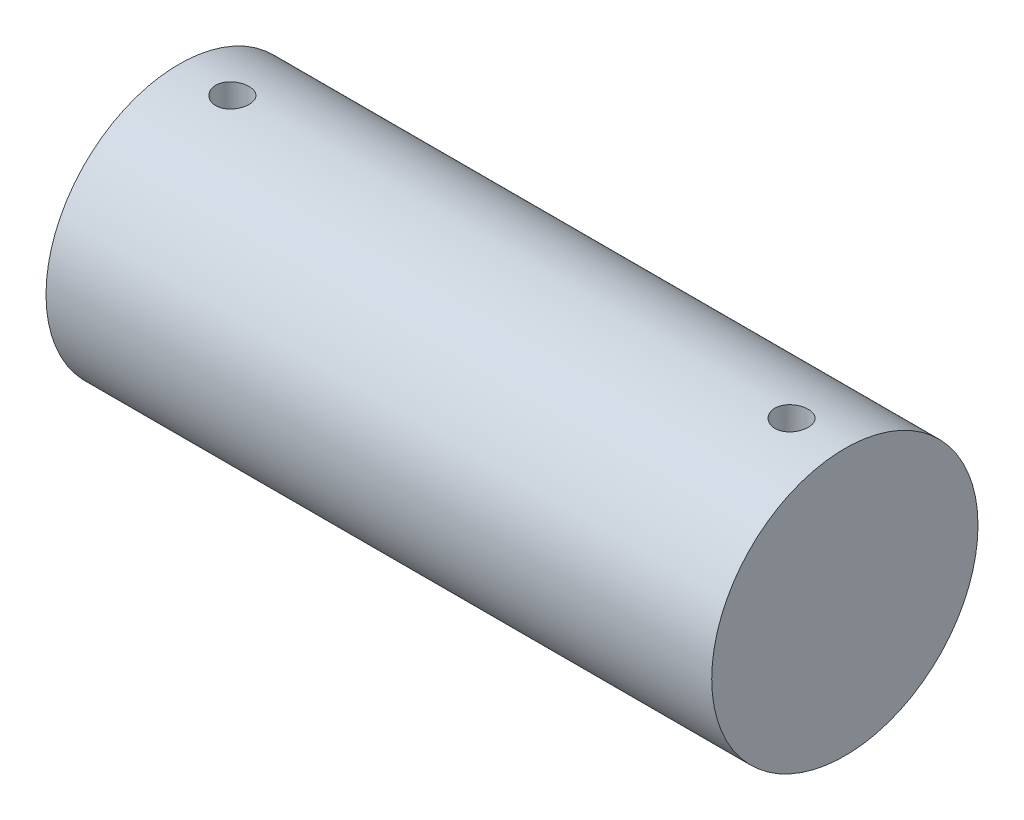
from build123d import *

# Parameters (mm, degrees)
IZIM1_R                     = 2
Y_KSEKLIK_EKSTR_ZYON1_DEPTH = 10
KES_EKSTR_ZYON1_DEPTH       = 10
KES_EKSTR_ZYON1_DEPTH_BACK  = 10
IZIM2_R                     = 0.25
L_EK1_SCALE                 = 0.5


with BuildPart() as part:
    # Çizim1 → Yükseklik-Ekstrüzyon1 (new body)
    with BuildSketch(Plane(origin=(0, 0, 0), x_dir=(0, 0, -1), z_dir=(1, 0, 0))):
        Circle(IZIM1_R)
    extrude(amount=Y_KSEKLIK_EKSTR_ZYON1_DEPTH)

    # Çizim2 → Kes-Ekstrüzyon1 (cut, two sides: drawn at the far end of the back side and taken through both)
    with BuildSketch(Plane(origin=(0, 0, 0), x_dir=(1, 0, 0), z_dir=(0, 1, 0)).offset(-KES_EKSTR_ZYON1_DEPTH_BACK)):
        with Locations((0.8, 0)):
            Circle(IZIM2_R)
        with Locations((9.2, 0)):
            Circle(IZIM2_R)
    extrude(amount=KES_EKSTR_ZYON1_DEPTH + KES_EKSTR_ZYON1_DEPTH_BACK, mode=Mode.SUBTRACT)


with BuildPart() as part_1:
    # Ölçek1: scaled about (4.999999983, 0, 4.1e-08)
    add(part.part.scale(L_EK1_SCALE).moved(Location((2.499999992, 0, 2.1e-08))))


solid = part_1.part
